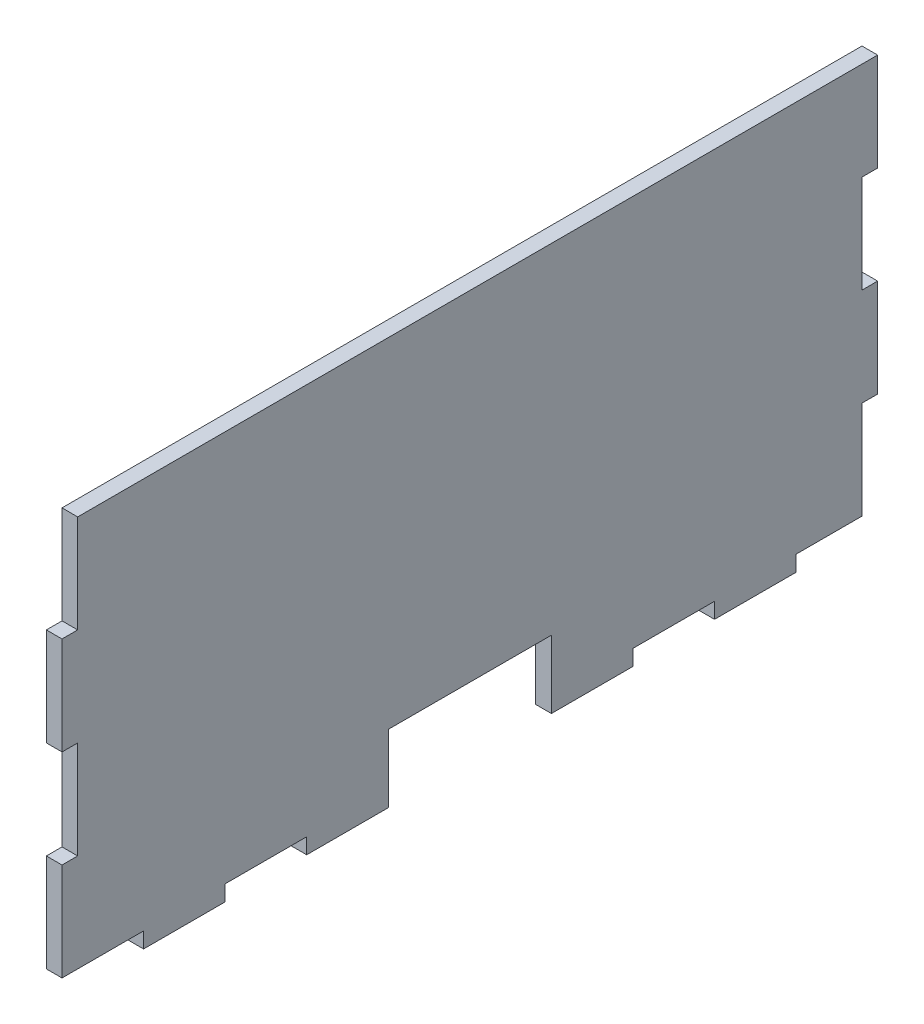
from build123d import *

# Parameters (mm, degrees)
BOSS_EXTRUDE1_DEPTH = 3.048


with BuildPart() as part:
    # Sketch2 → Boss-Extrude1 (new body)
    with BuildSketch(Plane(origin=(0, 0, 0), x_dir=(0, 0, -1), z_dir=(1, 0, 0))):
        Polygon((15.875, 3.048), (15.875, 0), (31.75, 0), (31.75, 3.048), (47.625, 3.048), (47.625, 0), (63.5, 0), (63.5, 3.048), (63.5, 13.208), (95.25, 13.208), (95.25, 3.048), (95.25, 0), (111.125, 0), (111.125, 3.048), (127, 3.048), (127, 0), (142.875, 0), (142.875, 3.048), (155.702, 3.048), (155.702, 22.098), (158.75, 22.098), (158.75, 41.148), (155.702, 41.148), (155.702, 60.198), (158.75, 60.198), (158.75, 79.248), (3.048, 79.248), (3.048, 60.198), (0, 60.198), (0, 41.148), (3.048, 41.148), (3.048, 22.098), (0, 22.098), (0, 3.048), align=None)
    extrude(amount=BOSS_EXTRUDE1_DEPTH)


solid = part.part
